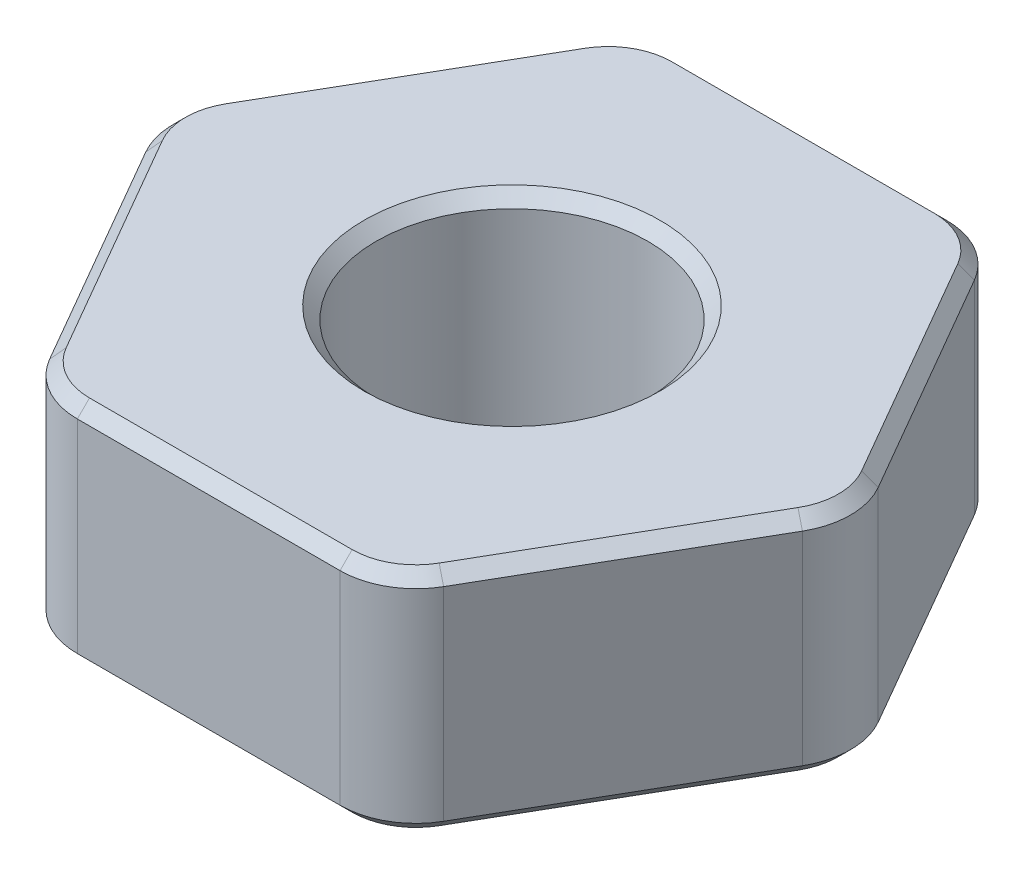
from build123d import *

# Parameters (mm, degrees)
SKETCH3_R           = 1.4224
BOSS_EXTRUDE1_DEPTH = 1.190625
FILLET1_R           = 0.79375
CHAMFER1_SIZE       = 0.127


with BuildPart() as part:
    # Sketch3 → Boss-Extrude1 (new body, symmetric)
    with BuildSketch(Plane(origin=(0, 0, 0), x_dir=(1, 0, 0), z_dir=(0, 1, 0))):
        Polygon((1.833087105, 3.175), (-1.833087105, 3.175), (-3.666174209, 0), (-1.833087105, -3.175), (1.833087105, -3.175), (3.666174209, 0), align=None)
        Circle(SKETCH3_R, mode=Mode.SUBTRACT)
    extrude(amount=BOSS_EXTRUDE1_DEPTH, both=True)

    # Fillet1
    fillet1_edges = [part.edges().sort_by_distance(p)[0] for p in [
        (3.666174209, 0, 0),
        (1.833087105, 0, 3.175),
        (-1.833087105, 0, 3.175),
        (-3.666174209, 0, 0),
        (-1.833087105, 0, -3.175),
        (1.833087105, 0, -3.175),
    ]]
    fillet(fillet1_edges, radius=FILLET1_R)

    # Chamfer1
    chamfer1_edges = [part.edges().sort_by_distance(p)[0] for p in [
        (-1.4224, -1.190625, 0),
        (-1.4224, 1.190625, 0),
        (2.749630657, -1.190625, -1.5875),
        (2.749630657, 1.190625, -1.5875),
        (2.749630657, -1.190625, 1.5875),
        (0, -1.190625, 3.175),
        (-2.749630657, -1.190625, 1.5875),
        (-2.749630657, -1.190625, -1.5875),
        (0, -1.190625, -3.175),
        (-1.771690329, -1.190625, 3.068657664),
        (1.771690329, -1.190625, -3.068657664),
        (-1.771690329, -1.190625, -3.068657664),
        (-3.543380657, -1.190625, 0),
        (1.771690329, -1.190625, 3.068657664),
        (3.543380657, -1.190625, 0),
        (2.749630657, 1.190625, 1.5875),
        (0, 1.190625, -3.175),
        (-2.749630657, 1.190625, -1.5875),
        (-2.749630657, 1.190625, 1.5875),
        (0, 1.190625, 3.175),
        (-1.771690329, 1.190625, 3.068657664),
        (1.771690329, 1.190625, -3.068657664),
        (-1.771690329, 1.190625, -3.068657664),
        (-3.543380657, 1.190625, 0),
        (1.771690329, 1.190625, 3.068657664),
        (3.543380657, 1.190625, 0),
    ]]
    chamfer(chamfer1_edges, length=CHAMFER1_SIZE)


solid = part.part
